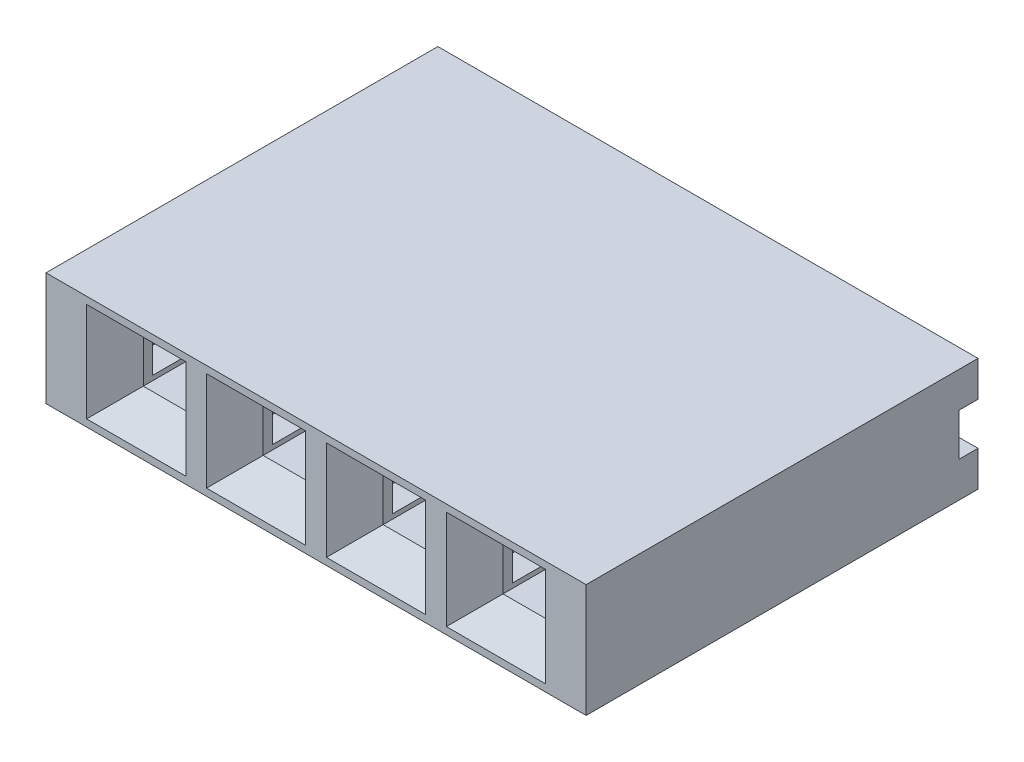
from build123d import *

# Parameters (mm, degrees)
SKETCH_218_W              = 2.54
SKETCH_218_H              = 2.4
EXTRUDE_695_DEPTH         = 6.7
EXTRUDE_695_DEPTH_BACK    = 0.4
SKETCH_749_W              = 2.54
SKETCH_749_H              = 0.75
EXTRUDE_1128_DEPTH        = 0.4
SKETCH_1182_W             = 2.54
SKETCH_1182_H             = 2.4
SKETCH_1182_W_2           = 0.9
SKETCH_1182_H_2           = 0.9
EXTRUDE_1467_DEPTH        = 0.8
CHAMFER_1528_SIZE         = 0.6
PATTERN_LINEAR_1654_COUNT = 4
PATTERN_LINEAR_1654_PITCH = 2.54
EXTRUDE_1_DEPTH           = 0.64
EXTRUDE_START             = -10.8
EXTRUDE_2_DEPTH           = 0.64


with BuildPart() as part:
    # Sketch 218 → Extrude 695 (new body, two sides)
    with BuildSketch(Plane.XY) as extrude_695_sk:
        Rectangle(SKETCH_218_W, SKETCH_218_H)
        Polygon((-1, 0.35), (-0.45, 0.35), (-0.45, 0.45), (0.45, 0.45), (0.45, 0.35), (1, 0.35), (1, -0.35), (0.45, -0.35), (0.45, -0.45), (-0.45, -0.45), (-0.45, -0.35), (-1, -0.35), align=None, mode=Mode.SUBTRACT)
    extrude(amount=EXTRUDE_695_DEPTH)
    extrude(extrude_695_sk.sketch, amount=-EXTRUDE_695_DEPTH_BACK)

    # Sketch 749 → Extrude 1128 (add)
    with BuildSketch(Plane(origin=(0, 0, -0.4), x_dir=(-1, 0, 0), z_dir=(0, 0, -1))):
        with Locations((0, -0.825)):
            Rectangle(SKETCH_749_W, SKETCH_749_H)
        with Locations((0, 0.825)):
            Rectangle(SKETCH_749_W, SKETCH_749_H)
    extrude(amount=EXTRUDE_1128_DEPTH)

    # Sketch 1182 → Extrude 1467 (add)
    with BuildSketch(Plane.XY.offset(6.7)):
        Rectangle(SKETCH_1182_W, SKETCH_1182_H)
        Rectangle(SKETCH_1182_W_2, SKETCH_1182_H_2, mode=Mode.SUBTRACT)
    extrude(amount=EXTRUDE_1467_DEPTH)

    # Chamfer 1528
    chamfer_1528_edges = [part.edges().sort_by_distance(p)[0] for p in [
        (0.45, 0, 7.5),
        (0, 0.45, 7.5),
        (-0.45, 0, 7.5),
        (0, -0.45, 7.5),
    ]]
    chamfer(chamfer_1528_edges, length=CHAMFER_1528_SIZE)


with BuildPart() as pattern_linear_1654_1:
    # Pattern Linear 1654: pattern copy
    add(part.part.moved(Location(Vector(-1, 0, 0) * (1 * PATTERN_LINEAR_1654_PITCH))))


with BuildPart() as pattern_linear_1654_2:
    # Pattern Linear 1654: pattern copy
    add(part.part.moved(Location(Vector(-1, 0, 0) * (2 * PATTERN_LINEAR_1654_PITCH))))


with BuildPart() as pattern_linear_1654_3:
    # Pattern Linear 1654: pattern copy
    add(part.part.moved(Location(Vector(-1, 0, 0) * (3 * PATTERN_LINEAR_1654_PITCH))))


with BuildPart() as part_1:
    add(part.part)

    # Combine 1770: union Pattern Linear 1654_3, Pattern Linear 1654_2, Pattern Linear 1654_1
    add(pattern_linear_1654_3.part)
    add(pattern_linear_1654_2.part)
    add(pattern_linear_1654_1.part)

    # Sketch 2578 → Бобышка-БоковаяНакладка1 (add)
    with BuildSketch(Plane(origin=(1.27, 0, 0), x_dir=(0, 0, -1), z_dir=(1, 0, 0))):
        Polygon((0.8, 1.2), (0.8, 0.45), (0.4, 0.45), (0.4, -0.45), (0.8, -0.45), (0.8, -1.2), (-7.5, -1.2), (-7.5, 1.2), align=None)
    extrude(amount=EXTRUDE_1_DEPTH)

    # Эскиз-БоковаяНакладка<2> → Бобышка-БоковаяНакладка2 (add)
    with BuildSketch(Plane(origin=(1.27, 0, 0), x_dir=(0, 0, -1), z_dir=(1, 0, 0)).offset(EXTRUDE_START)):
        Polygon((0.8, 1.2), (0.8, 0.45), (0.4, 0.45), (0.4, -0.45), (0.8, -0.45), (0.8, -1.2), (-7.5, -1.2), (-7.5, 1.2), align=None)
    extrude(amount=EXTRUDE_2_DEPTH)


solid = part_1.part
